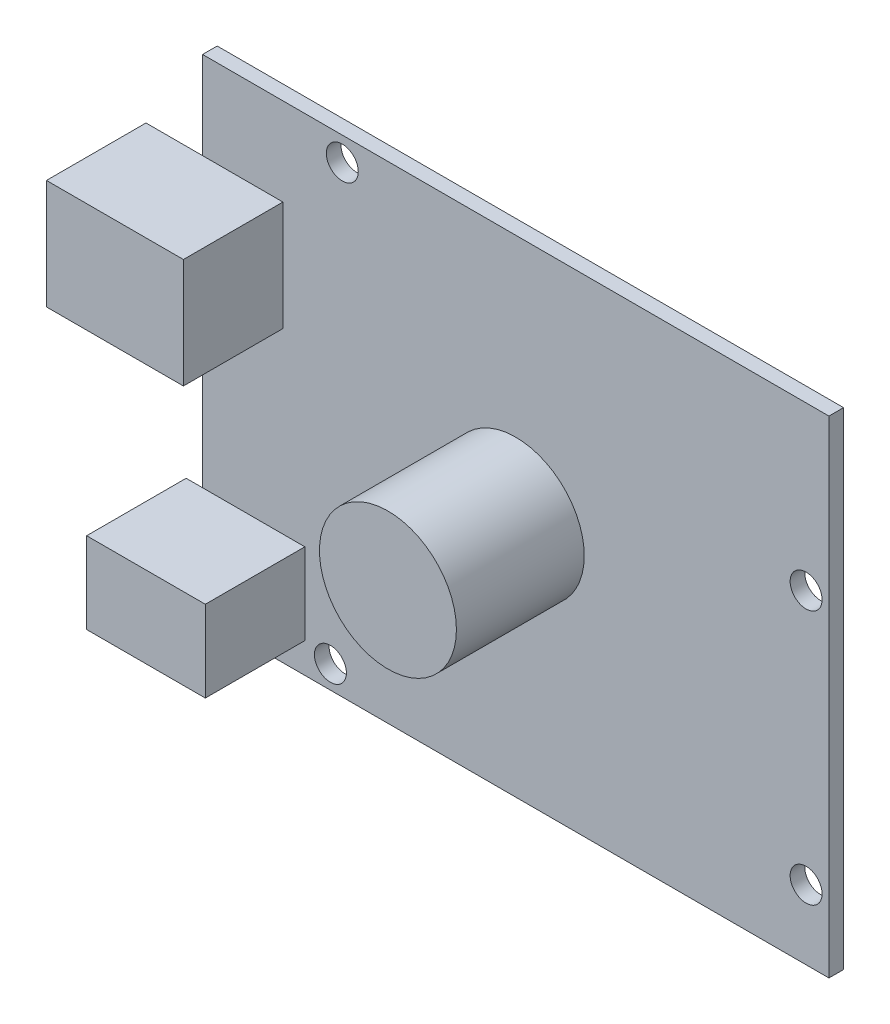
from build123d import *

# Parameters (mm, degrees)
SKETCH1_W           = 68.6
SKETCH1_H           = 53.3
BOSS_EXTRUDE1_DEPTH = 1.6
SKETCH2_W           = 15
SKETCH2_H           = 12
SKETCH2_W_2         = 13
SKETCH2_H_2         = 8.9
BOSS_EXTRUDE2_DEPTH = 10.9
SKETCH3_R           = 1.75
CUT_EXTRUDE1_DEPTH  = 2.6
SKETCH4_R           = 7.5
BOSS_EXTRUDE3_DEPTH = 14


with BuildPart() as part:
    # Sketch1 → Boss-Extrude1 (new body)
    with BuildSketch(Plane.XY):
        Rectangle(SKETCH1_W, SKETCH1_H)
    extrude(amount=BOSS_EXTRUDE1_DEPTH)

    # Sketch2 → Boss-Extrude2 (add)
    with BuildSketch(Plane.XY.offset(1.6)):
        with Locations((-33, 11.05)):
            Rectangle(SKETCH2_W, SKETCH2_H)
        with Locations((-29.6, -18.9)):
            Rectangle(SKETCH2_W_2, SKETCH2_H_2)
    extrude(amount=BOSS_EXTRUDE2_DEPTH)

    # Sketch3 → Cut-Extrude1 (cut, through all)
    with BuildSketch(Plane.XY.offset(1.6)):
        with Locations((-19, 24.05)):
            Circle(SKETCH3_R)
        with Locations((-20.3, -24.15)):
            Circle(SKETCH3_R)
        with Locations((31.8, -19.05)):
            Circle(SKETCH3_R)
        with Locations((31.8, 8.85)):
            Circle(SKETCH3_R)
    extrude(amount=-CUT_EXTRUDE1_DEPTH, mode=Mode.SUBTRACT)

    # Sketch4 → Boss-Extrude3 (add)
    with BuildSketch(Plane.XY.offset(1.6)):
        Circle(SKETCH4_R)
    extrude(amount=BOSS_EXTRUDE3_DEPTH)


solid = part.part
